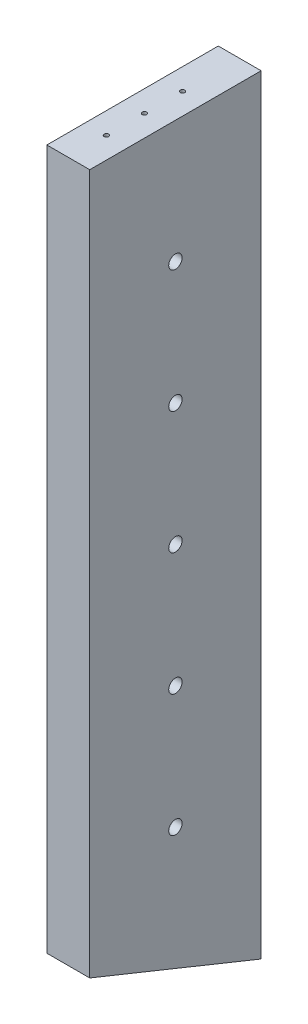
from build123d import *

# Parameters (mm, degrees)
SKETCH1_W                            = 19.05
SKETCH1_H                            = 341.988103331
BOSS_EXTRUDE1_DEPTH                  = 76.2
CUT_EXTRUDE1_REACH                   = 21.05
F_5_64_0_07813_DIAMETER_HOLE1_D      = 1.984502
F_5_64_0_07813_DIAMETER_HOLE1_DEPTH  = 38.1
F_5_64_0_07813_DIAMETER_HOLE1_TIP    = 0.59620455
F_5_64_0_07813_DIAMETER_HOLE2_D      = 1.984502
F_5_64_0_07813_DIAMETER_HOLE2_DEPTH  = 38.1
F_5_64_0_07813_DIAMETER_HOLE2_TIP    = 0.59620455
F_5_64_0_07813_DIAMETER_HOLE3_D      = 1.984502
F_5_64_0_07813_DIAMETER_HOLE3_DEPTH  = 19.05
F_5_64_0_07813_DIAMETER_HOLE3_TIP    = 0.59620455
F_5_64_0_07813_DIAMETER_HOLE4_D      = 1.984502
F_5_64_0_07813_DIAMETER_HOLE4_DEPTH  = 19.05
F_5_64_0_07813_DIAMETER_HOLE4_TIP    = 0.59620455
F_15_64_0_23438_DIAMETER_HOLE1_D     = 5.953252
F_15_64_0_23438_DIAMETER_HOLE1_DEPTH = 19.05


with BuildPart() as part:
    # Sketch1 → Boss-Extrude1 (new body)
    with BuildSketch(Plane.XY):
        with Locations((485.002307398, 6812.735938475)):
            Rectangle(SKETCH1_W, SKETCH1_H)
    extrude(amount=BOSS_EXTRUDE1_DEPTH)

    # Sketch2 → Cut-Extrude1 (cut, up to next)
    with BuildSketch(Plane(origin=(494.527307398, 0, 0), x_dir=(0, 0, -1), z_dir=(1, 0, 0)), mode=Mode.PRIVATE) as cut_extrude1_sk1:
        Polygon((0, 6641.741886809), (-76.2, 6672.528685257), (-76.2, 6641.741886809), align=None)
    cut_extrude1_tool1 = extrude(cut_extrude1_sk1.sketch, amount=-CUT_EXTRUDE1_REACH, mode=Mode.PRIVATE) & part.part
    add(cut_extrude1_tool1.solids().sort_by_distance((494.527307, 6652.004153, 50.8))[0], mode=Mode.SUBTRACT)

    # 5/64 (0.07813) Diameter Hole1
    with Locations(Plane(origin=(0, -8e-09, -19.049996974), x_dir=(-1, 0, 0), z_dir=(0, 0, -1))):
        with Locations((-481.589248274, 6993.254992531), (-386.339248274, 6993.254992531), (-291.089248274, 6993.254992531), (-295.274999999, 6965.135938475), (-295.274999999, 6812.735938475), (-295.274999999, 6660.335938474), (-285.166362357, 6631.468843414), (-475.477307398, 6631.468752771), (-485.002307398, 6660.335938474), (-485.002307398, 6812.735938474), (-485.002307398, 6965.135938474), (-478.365617646, 6611.6708), (-287.865617646, 6611.6708), (-307.975, 6564.3379), (-307.975, 6488.1379), (-284.960913066, 6440.805), (-380.210913066, 6440.805), (-475.460913066, 6440.805), (-446.831312422, 6488.1379), (-446.831312422, 6564.3379), (-472.231312422, 6396.355), (-472.231312422, 6320.155), (-472.653156211, 6275.705000839), (-377.403156211, 6275.705000839), (-282.153156211, 6275.705000839), (-282.575, 6320.155), (-282.575, 6396.355), (-435.598646187, 6221.729999816), (-435.598646187, 6145.529999816), (-450.592518112, 6091.554999951), (-460.998646187, 6091.555478285), (-460.998646187, 6056.629999944), (-460.998646187, 5980.429999944), (-460.998646187, 5945.505000042), (-282.153156211, 5945.505000042), (-368.611823093, 5945.505000042)):
            Hole(F_5_64_0_07813_DIAMETER_HOLE1_D / 2, depth=F_5_64_0_07813_DIAMETER_HOLE1_DEPTH)
            with Locations((0, 0, -(F_5_64_0_07813_DIAMETER_HOLE1_DEPTH + F_5_64_0_07813_DIAMETER_HOLE1_TIP / 2))):  # 118° drill point
                Cone(0, F_5_64_0_07813_DIAMETER_HOLE1_D / 2, F_5_64_0_07813_DIAMETER_HOLE1_TIP, mode=Mode.SUBTRACT)

    # 5/64 (0.07813) Diameter Hole2
    with Locations(Plane(origin=(189.727307399, 0, -19.050000054), x_dir=(-1, 0, 0), z_dir=(0, 0, -1))):
        with Locations((-481.589248274, 6993.254992531), (-386.339248274, 6993.254992531), (-291.089248274, 6993.254992531), (-295.274999999, 6965.135938475), (-295.274999999, 6812.735938475), (-295.274999999, 6660.335938474), (-285.166362357, 6631.468843414), (-475.477307398, 6631.468752771), (-485.002307398, 6660.335938474), (-485.002307398, 6812.735938474), (-485.002307398, 6965.135938474), (-478.365617646, 6611.6708), (-287.865617646, 6611.6708), (-307.975, 6564.3379), (-307.975, 6488.1379), (-284.960913066, 6440.805), (-380.210913066, 6440.805), (-475.460913066, 6440.805), (-446.831312422, 6488.1379), (-446.831312422, 6564.3379), (-472.231312422, 6396.355), (-472.231312422, 6320.155), (-472.653156211, 6275.705000839), (-377.403156211, 6275.705000839), (-282.153156211, 6275.705000839), (-282.575, 6320.155), (-282.575, 6396.355), (-435.598646187, 6221.729999816), (-435.598646187, 6145.529999816), (-450.592518112, 6091.554999951), (-460.998646187, 6091.555478285), (-460.998646187, 6056.629999944), (-460.998646187, 5980.429999944), (-460.998646187, 5945.505000042), (-282.153156211, 5945.505000042), (-368.611823093, 5945.505000042)):
            Hole(F_5_64_0_07813_DIAMETER_HOLE2_D / 2, depth=F_5_64_0_07813_DIAMETER_HOLE2_DEPTH)
            with Locations((0, 0, -(F_5_64_0_07813_DIAMETER_HOLE2_DEPTH + F_5_64_0_07813_DIAMETER_HOLE2_TIP / 2))):  # 118° drill point
                Cone(0, F_5_64_0_07813_DIAMETER_HOLE2_D / 2, F_5_64_0_07813_DIAMETER_HOLE2_TIP, mode=Mode.SUBTRACT)

    # 5/64 (0.07813) Diameter Hole3
    with Locations(Plane(origin=(-4e-09, 6983.72999014, 0), x_dir=(1, 0, 0), z_dir=(0, 1, 0))):
        with Locations((485.002307402, -59.266666667), (485.002307402, -25.4), (485.002307402, -42.333333333)):
            Hole(F_5_64_0_07813_DIAMETER_HOLE3_D / 2, depth=F_5_64_0_07813_DIAMETER_HOLE3_DEPTH)
            with Locations((0, 0, -(F_5_64_0_07813_DIAMETER_HOLE3_DEPTH + F_5_64_0_07813_DIAMETER_HOLE3_TIP / 2))):  # 118° drill point
                Cone(0, F_5_64_0_07813_DIAMETER_HOLE3_D / 2, F_5_64_0_07813_DIAMETER_HOLE3_TIP, mode=Mode.SUBTRACT)

    # 5/64 (0.07813) Diameter Hole4
    with Locations(Plane(origin=(0, 5709.705582748, -2306.870800158), x_dir=(-1, 0, 0), z_dir=(0, -0.927183854, 0.374606594))):
        with Locations((-485.002307398, -2519.790305282), (-485.002307398, -2553.413203553), (-485.002307398, -2536.601754417)):
            Hole(F_5_64_0_07813_DIAMETER_HOLE4_D / 2, depth=F_5_64_0_07813_DIAMETER_HOLE4_DEPTH)
            with Locations((0, 0, -(F_5_64_0_07813_DIAMETER_HOLE4_DEPTH + F_5_64_0_07813_DIAMETER_HOLE4_TIP / 2))):  # 118° drill point
                Cone(0, F_5_64_0_07813_DIAMETER_HOLE4_D / 2, F_5_64_0_07813_DIAMETER_HOLE4_TIP, mode=Mode.SUBTRACT)

    # 15/64 (0.23438) Diameter Hole1
    with Locations(Plane.ZY.offset(-475.477307398)):
        with Locations((38.1, 6711.567736717), (38.1, 6929.297539455), (38.1, 6874.865088771), (38.1, 6820.432638086), (38.1, 6766.000187402)):
            Hole(F_15_64_0_23438_DIAMETER_HOLE1_D / 2, depth=F_15_64_0_23438_DIAMETER_HOLE1_DEPTH)


solid = part.part
